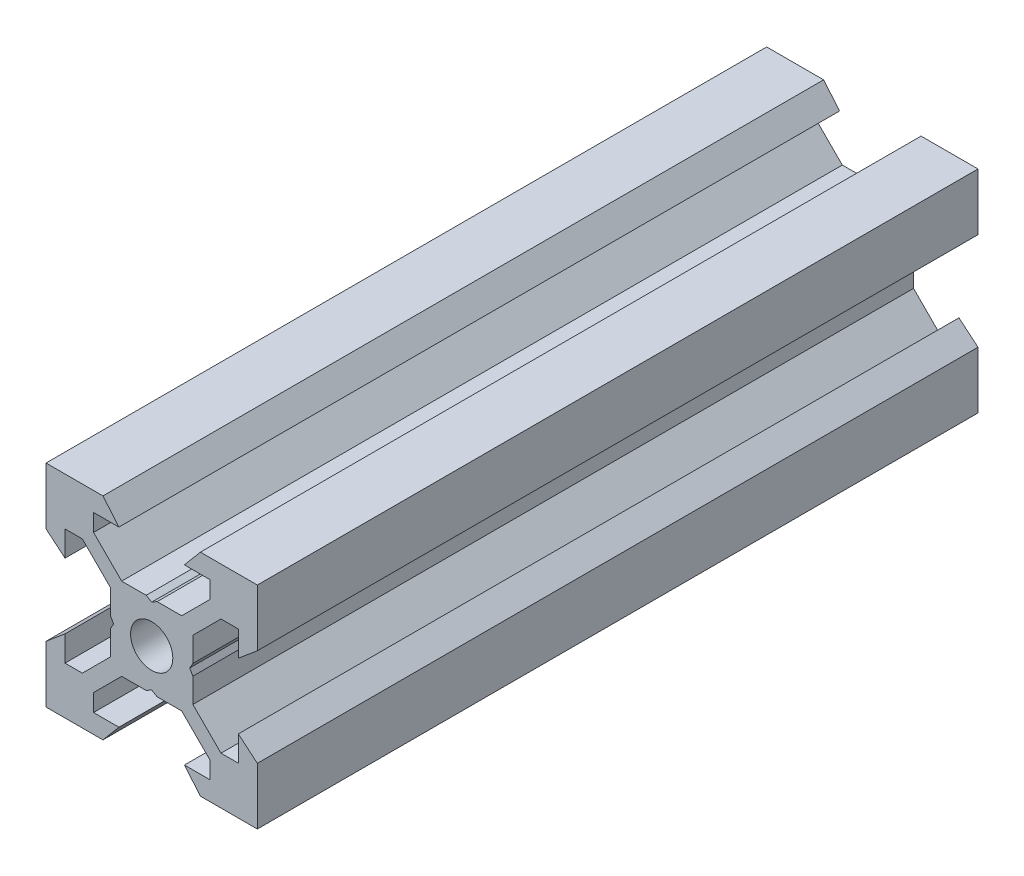
from build123d import *

# Parameters (mm, degrees)
SKETCH1_R           = 2
BOSS_EXTRUDE1_DEPTH = 34.1


with BuildPart() as part:
    # Sketch1 → Boss-Extrude1 (new body, symmetric)
    with BuildSketch(Plane.XY):
        Polygon((10, 10), (10, 4.610379336), (8.2, 3.1), (8.2, 5.5), (6.560660172, 5.5), (3.9, 2.839339828), (3.9, 0.519615242), (3.6, 0), (3.9, -0.519615242), (3.9, -2.839339828), (6.560660172, -5.5), (8.2, -5.5), (8.2, -3.1), (10, -4.610379336), (10, -10), (4.610379336, -10), (3.1, -8.2), (5.5, -8.2), (5.5, -6.560660172), (2.839339828, -3.9), (0.519615242, -3.9), (0, -3.6), (-0.519615242, -3.9), (-2.839339828, -3.9), (-5.5, -6.560660172), (-5.5, -8.2), (-3.1, -8.2), (-4.610379336, -10), (-10, -10), (-10, -4.610379336), (-8.2, -3.1), (-8.2, -5.5), (-6.560660172, -5.5), (-3.9, -2.839339828), (-3.9, -0.519615242), (-3.6, 0), (-3.9, 0.519615242), (-3.9, 2.839339828), (-6.560660172, 5.5), (-8.2, 5.5), (-8.2, 3.1), (-10, 4.610379336), (-10, 10), (-4.610379336, 10), (-3.1, 8.2), (-5.5, 8.2), (-5.5, 6.560660172), (-2.839339828, 3.9), (-0.519615242, 3.9), (0, 3.6), (0.519615242, 3.9), (2.839339828, 3.9), (5.5, 6.560660172), (5.5, 8.2), (3.1, 8.2), (4.610379336, 10), align=None)
        Circle(SKETCH1_R, mode=Mode.SUBTRACT)
    extrude(amount=BOSS_EXTRUDE1_DEPTH, both=True)


solid = part.part
